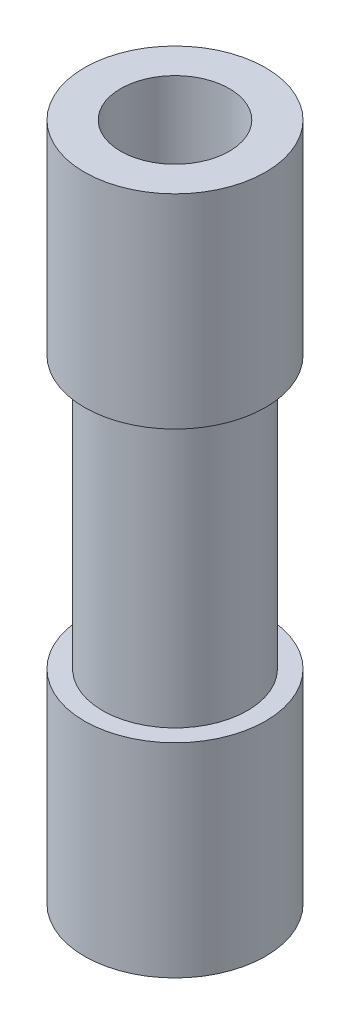
from build123d import *

# Parameters (mm, degrees)
SKETCH2_R               = 1
BOSS_EXTRUDE1_DEPTH     = 7.5
SKETCH4_OUTSIDE_W       = 5.604
SKETCH4_OUTSIDE_H       = 5.604
SKETCH4_OUTSIDE_R       = 0.8
CUT_EXTRUDE1_DEPTH      = 1.5
CUT_EXTRUDE1_DEPTH_BACK = 1.5
SKETCH5_R               = 0.6
CUT_EXTRUDE2_DEPTH      = 7.5


with BuildPart() as part:
    # Sketch2 → Boss-Extrude1 (new body)
    with BuildSketch(Plane(origin=(0, 0, 0), x_dir=(1, 0, 0), z_dir=(0, 1, 0))):
        Circle(SKETCH2_R)
    extrude(amount=BOSS_EXTRUDE1_DEPTH)

    # Sketch4 outside → Cut-Extrude1 (cut, two sides)
    with BuildSketch(Plane(origin=(0, 3.75, 0), x_dir=(1, 0, 0), z_dir=(0, 1, 0))) as cut_extrude1_sk:
        Rectangle(SKETCH4_OUTSIDE_W, SKETCH4_OUTSIDE_H)
        Circle(SKETCH4_OUTSIDE_R, mode=Mode.SUBTRACT)
    extrude(amount=CUT_EXTRUDE1_DEPTH, mode=Mode.SUBTRACT)
    extrude(cut_extrude1_sk.sketch, amount=-CUT_EXTRUDE1_DEPTH_BACK, mode=Mode.SUBTRACT)

    # Sketch5 → Cut-Extrude2 (cut)
    with BuildSketch(Plane(origin=(0, 7.5, 0), x_dir=(1, 0, 0), z_dir=(0, 1, 0))):
        Circle(SKETCH5_R)
    extrude(amount=-CUT_EXTRUDE2_DEPTH, mode=Mode.SUBTRACT)


solid = part.part
